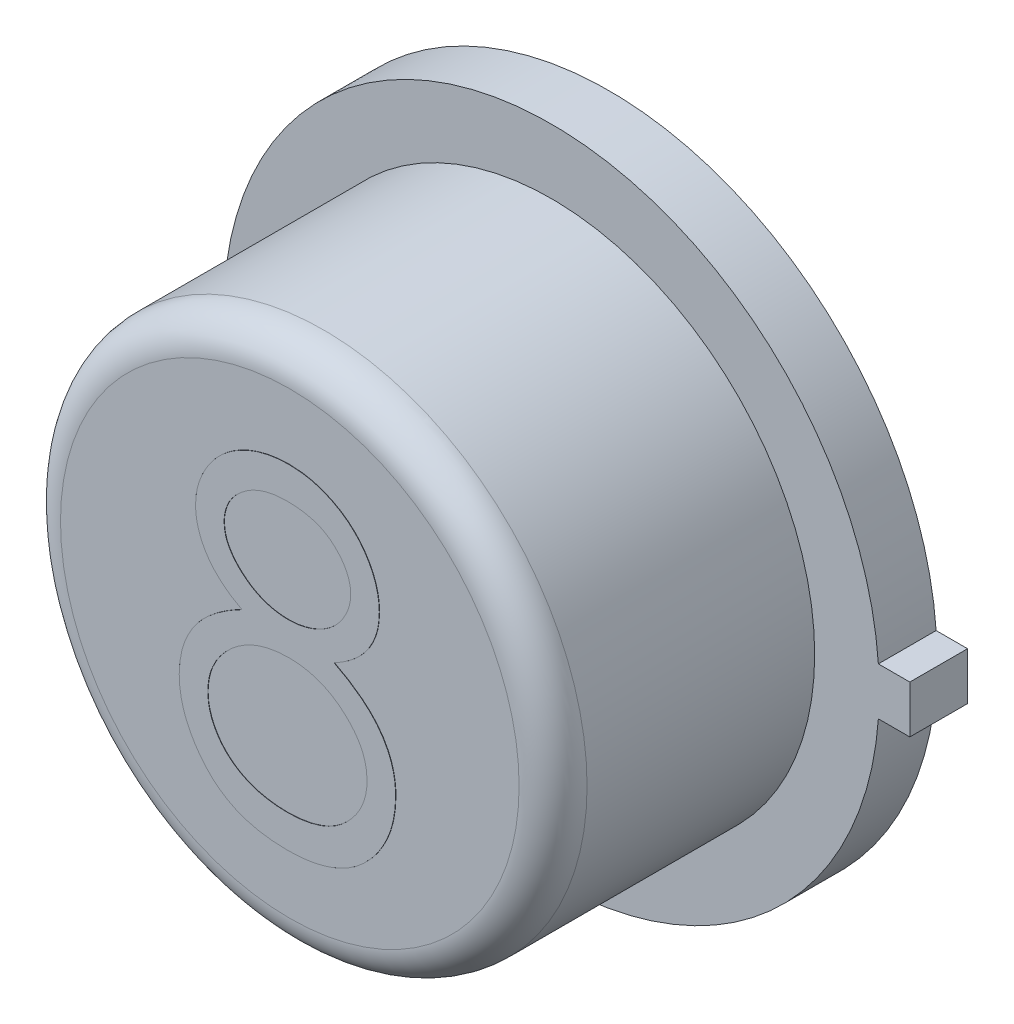
from build123d import *

# Parameters (mm, degrees)
BOSS_EXTRUDE1_DEPTH = 0.4318
SKETCH2_R           = 1.9685
BOSS_EXTRUDE2_DEPTH = 1.9558
SKETCH3_R           = 1.757566481
BOSS_EXTRUDE3_DEPTH = 0.00254
FILLET1_R           = 0.254
BOSS_EXTRUDE6_DEPTH = 0.00254


with BuildPart() as part:
    # Sketch1 → Boss-Extrude1 (new body)
    with BuildSketch(Plane.XY):
        with BuildLine():
            Line((2.6797, 0.1778), (2.4511, 0.1778))
            Line((2.4511, 0.1778), (2.44464279, 0.1778))
            ThreePointArc((2.44464279, 0.1778), (-2.4511, 0), (2.44464279, -0.1778))
            Line((2.44464279, -0.1778), (2.4511, -0.1778))
            Line((2.4511, -0.1778), (2.6797, -0.1778))
            Line((2.6797, -0.1778), (2.6797, 0.1778))
        make_face()
    extrude(amount=BOSS_EXTRUDE1_DEPTH)

    # Sketch2 → Boss-Extrude2 (add)
    with BuildSketch(Plane.XY.offset(0.4318)):
        Circle(SKETCH2_R)
    extrude(amount=BOSS_EXTRUDE2_DEPTH)

    # Sketch3 → Boss-Extrude3 (add)
    with BuildSketch(Plane(origin=(0, 0, 0), x_dir=(-1, 0, 0), z_dir=(0, 0, -1))):
        Circle(SKETCH3_R)
    extrude(amount=BOSS_EXTRUDE3_DEPTH)

    # Fillet1
    fillet1_edges = [part.edges().sort_by_distance(p)[0] for p in [
        (-1.9685, 0, 2.3876),
    ]]
    fillet(fillet1_edges, radius=FILLET1_R)

    # Sketch4 → Boss-Extrude6 (add)
    with BuildSketch(Plane.XY.offset(2.3876)):
        with BuildLine():
            add(Edge.make_bspline(
                [(0.333432242, 0.108432561), (0.352923485, 0.098269416), (0.39093792, 0.078447889), (0.445078842, 0.046531772), (0.494557816, 0.012894259), (0.540747645, -0.020875853), (0.582836817, -0.056071851), (0.620354712, -0.092833695), (0.654228075, -0.130243776), (0.683773798, -0.168935578), (0.709761289, -0.208806309), (0.732221331, -0.249960617), (0.751419106, -0.292308314), (0.766633891, -0.336311657), (0.779167289, -0.381324264), (0.787791227, -0.427927355), (0.792429166, -0.475813844), (0.793306019, -0.508177278), (0.79375, -0.524563983)],
                knots=[0, 0, 0, 0, 6.594e-05, 0.000128605, 0.000188405, 0.000245362, 0.000300208, 0.000352831, 0.000402824, 0.000451482, 0.000498716, 0.000545466, 0.00059201, 0.000638024, 0.000685007, 0.000732067, 0.000780006, 0.000829176, 0.000829176, 0.000829176, 0.000829176], degree=3))
            add(Edge.make_bspline(
                [(0.79375, -0.524563983), (0.793225159, -0.547490476), (0.7921863, -0.592870609), (0.783137561, -0.659849124), (0.769589624, -0.724899283), (0.74980517, -0.788006824), (0.724146595, -0.848823522), (0.692525748, -0.907401438), (0.656731339, -0.964700646), (0.627984726, -0.999956346), (0.613439002, -1.017795654)],
                knots=[0, 0, 0, 0, 6.875e-05, 0.000136081, 0.000202413, 0.000267891, 0.00033416, 0.0004001, 0.000467454, 0.000536443, 0.000536443, 0.000536443, 0.000536443], degree=3))
            add(Edge.make_bspline(
                [(0.613439002, -1.017795654), (0.594500258, -1.038610347), (0.556856801, -1.079982519), (0.49237056, -1.133697267), (0.421598528, -1.178838551), (0.344814555, -1.215626751), (0.262223891, -1.244260166), (0.173844135, -1.264835879), (0.079502988, -1.276621317), (0.01466123, -1.278324924), (-0.018603516, -1.279198899)],
                knots=[0, 0, 0, 0, 8.4349e-05, 0.000167656, 0.000250888, 0.000335588, 0.000422483, 0.000512618, 0.000607343, 0.000707132, 0.000707132, 0.000707132, 0.000707132], degree=3))
            add(Edge.make_bspline(
                [(-0.018603516, -1.279198899), (-0.05058941, -1.278414803), (-0.112830713, -1.27688903), (-0.203425626, -1.26655139), (-0.287873643, -1.248434931), (-0.366665782, -1.223639581), (-0.439327036, -1.191383693), (-0.50565036, -1.151236901), (-0.566592652, -1.104815152), (-0.620304449, -1.050785216), (-0.667989623, -0.992915485), (-0.709877887, -0.933213051), (-0.744694537, -0.871672463), (-0.774172436, -0.809211345), (-0.796738537, -0.74495423), (-0.812367844, -0.679231721), (-0.822293788, -0.612158615), (-0.823614453, -0.566893329), (-0.824278846, -0.544121525)],
                knots=[0, 0, 0, 0, 9.5956e-05, 0.00018672, 0.000273075, 0.000354689, 0.00043412, 0.000510937, 0.000586788, 0.000663356, 0.000738906, 0.000811553, 0.000881843, 0.000950774, 0.001018511, 0.001085731, 0.001153191, 0.001221486, 0.001221486, 0.001221486, 0.001221486], degree=3))
            add(Edge.make_bspline(
                [(-0.824278846, -0.544121525), (-0.823885681, -0.527412504), (-0.823108647, -0.494389579), (-0.817730527, -0.445601625), (-0.809084235, -0.398115327), (-0.79734164, -0.351755285), (-0.781427388, -0.306859012), (-0.762212651, -0.263213779), (-0.739807162, -0.220770312), (-0.713898369, -0.179296502), (-0.683757171, -0.139373476), (-0.649627973, -0.100323701), (-0.610828655, -0.06275311), (-0.567790855, -0.026202674), (-0.52100641, 0.00997598), (-0.469260126, 0.043827645), (-0.413923776, 0.077748867), (-0.374595455, 0.098029174), (-0.354420823, 0.108432561)],
                knots=[0, 0, 0, 0, 5.0123e-05, 9.906e-05, 0.000147059, 0.000194841, 0.000242363, 0.00028978, 0.00033779, 0.00038623, 0.000436316, 0.000487697, 0.000541669, 0.000598168, 0.000657034, 0.000718951, 0.000783578, 0.000851651, 0.000851651, 0.000851651, 0.000851651], degree=3))
            add(Edge.make_bspline(
                [(-0.354420823, 0.108432561), (-0.382037455, 0.123492109), (-0.435510984, 0.152651609), (-0.506315371, 0.206227561), (-0.567132921, 0.264253735), (-0.616291934, 0.327955435), (-0.65498536, 0.395342683), (-0.681531947, 0.465993862), (-0.699490983, 0.538598932), (-0.70127, 0.588201184), (-0.702163462, 0.613112549)],
                knots=[0, 0, 0, 0, 9.4253e-05, 0.000182501, 0.000265487, 0.000345731, 0.000423061, 0.000497652, 0.000571591, 0.00064619, 0.00064619, 0.00064619, 0.00064619], degree=3))
            add(Edge.make_bspline(
                [(-0.702163462, 0.613112549), (-0.701050789, 0.638488209), (-0.698814123, 0.689497712), (-0.680727971, 0.765429735), (-0.651254855, 0.840008148), (-0.611167533, 0.912871481), (-0.561238017, 0.981553681), (-0.50133492, 1.04315386), (-0.432888749, 1.097113994), (-0.356241164, 1.142409569), (-0.273757225, 1.179273808), (-0.186728849, 1.204704485), (-0.09667236, 1.221329771), (-0.035373733, 1.223212085), (-0.004293119, 1.224166485)],
                knots=[0, 0, 0, 0, 7.6061e-05, 0.000152895, 0.000232796, 0.000316055, 0.000401733, 0.000486743, 0.000573013, 0.000662428, 0.000753193, 0.000843293, 0.000933872, 0.001027038, 0.001027038, 0.001027038, 0.001027038], degree=3))
            add(Edge.make_bspline(
                [(-0.004293119, 1.224166485), (0.025985369, 1.223182456), (0.085691099, 1.221242061), (0.173453515, 1.205058488), (0.257426512, 1.178028226), (0.337320511, 1.141358865), (0.411705228, 1.096192036), (0.477429299, 1.041490727), (0.535485931, 0.980162279), (0.583508527, 0.911500906), (0.623080065, 0.838917553), (0.650635142, 0.762974373), (0.668291753, 0.685312246), (0.67051881, 0.632762818), (0.671634615, 0.606434364)],
                knots=[0, 0, 0, 0, 9.0784e-05, 0.000179016, 0.000266663, 0.000354818, 0.000442194, 0.000526906, 0.0006106, 0.000694776, 0.00077758, 0.000857866, 0.000936459, 0.001015374, 0.001015374, 0.001015374, 0.001015374], degree=3))
            add(Edge.make_bspline(
                [(0.671634615, 0.606434364), (0.670658602, 0.580596669), (0.668741767, 0.529852906), (0.652617343, 0.455880041), (0.625462035, 0.38660469), (0.588386542, 0.32124077), (0.540063845, 0.260973716), (0.481138975, 0.205037153), (0.412081719, 0.152971579), (0.36019708, 0.123589428), (0.333432242, 0.108432561)],
                knots=[0, 0, 0, 0, 7.7454e-05, 0.000152115, 0.000225817, 0.000299952, 0.000376684, 0.000456642, 0.000543172, 0.000635369, 0.000635369, 0.000635369, 0.000635369], degree=3))
        make_face()
        with BuildLine():
            add(Edge.make_bspline(
                [(-0.01621845, 0.979935716), (-0.032921766, 0.979492504), (-0.065600756, 0.978625387), (-0.113517405, 0.974095136), (-0.159082533, 0.965282322), (-0.202772212, 0.953553842), (-0.24398744, 0.937709693), (-0.283287967, 0.919071302), (-0.32000493, 0.896411283), (-0.354581567, 0.870992325), (-0.385708433, 0.843034473), (-0.41333403, 0.813905853), (-0.436281193, 0.783034381), (-0.455767376, 0.751187979), (-0.46990623, 0.717421462), (-0.480495516, 0.682770073), (-0.487653819, 0.646795927), (-0.488190206, 0.622210194), (-0.488461538, 0.609773457)],
                knots=[0, 0, 0, 0, 5.0123e-05, 9.8062e-05, 0.000144184, 0.000189201, 0.000233586, 0.00027647, 0.000319502, 0.000362815, 0.000405044, 0.000444868, 0.000483029, 0.000520251, 0.00055658, 0.000592492, 0.000628886, 0.000666142, 0.000666142, 0.000666142, 0.000666142], degree=3))
            add(Edge.make_bspline(
                [(-0.488461538, 0.609773457), (-0.487993883, 0.597336181), (-0.48706973, 0.572758339), (-0.479922491, 0.536464098), (-0.469270238, 0.500798663), (-0.452498985, 0.466610097), (-0.432383301, 0.432712418), (-0.407556065, 0.399952823), (-0.377967994, 0.368217302), (-0.344611825, 0.337775782), (-0.308272904, 0.30926966), (-0.269775546, 0.284522906), (-0.229602912, 0.263816841), (-0.188167754, 0.2465838), (-0.145047775, 0.23318761), (-0.100507192, 0.223683942), (-0.05453852, 0.217777084), (-0.023391374, 0.217071539), (-0.007632212, 0.216714562)],
                knots=[0, 0, 0, 0, 3.7283e-05, 7.3677e-05, 0.000110642, 0.000148624, 0.000187564, 0.000228778, 0.000271648, 0.000317566, 0.00036413, 0.000410045, 0.000454635, 0.000499547, 0.000544508, 0.000589885, 0.000636034, 0.000683297, 0.000683297, 0.000683297, 0.000683297], degree=3))
            add(Edge.make_bspline(
                [(-0.007632212, 0.216714562), (0.012608484, 0.217308424), (0.052889959, 0.218490281), (0.112271076, 0.229478847), (0.170007982, 0.246763945), (0.225483558, 0.270413136), (0.277261856, 0.300095662), (0.323417331, 0.335632769), (0.363556289, 0.376203893), (0.397261597, 0.421177429), (0.42339401, 0.469041635), (0.443737919, 0.517075048), (0.455617781, 0.565790137), (0.45716734, 0.598424804), (0.457932692, 0.614543589)],
                knots=[0, 0, 0, 0, 6.0673e-05, 0.000120746, 0.000180508, 0.000241201, 0.000301256, 0.000359075, 0.000415405, 0.000471979, 0.000527067, 0.000578622, 0.000628142, 0.000676471, 0.000676471, 0.000676471, 0.000676471], degree=3))
            add(Edge.make_bspline(
                [(0.457932692, 0.614543589), (0.457570812, 0.625856592), (0.456852531, 0.648311281), (0.450933386, 0.681470776), (0.441152686, 0.713875904), (0.42791084, 0.745794363), (0.410487033, 0.776778325), (0.389828541, 0.807314855), (0.364733907, 0.836717008), (0.336569548, 0.86566998), (0.304629904, 0.892465181), (0.268976528, 0.916029154), (0.229792209, 0.936040061), (0.187076019, 0.952292946), (0.140985276, 0.964500151), (0.091732267, 0.973641667), (0.038906313, 0.978794087), (0.002555, 0.97954692), (-0.01621845, 0.979935716)],
                knots=[0, 0, 0, 0, 3.3922e-05, 6.733e-05, 0.000100683, 0.000135322, 0.000170765, 0.00020715, 0.00024575, 0.000286564, 0.000328218, 0.000370554, 0.000414501, 0.000459948, 0.000507391, 0.000557352, 0.000610085, 0.000666405, 0.000666405, 0.000666405, 0.000666405], degree=3))
        make_face(mode=Mode.SUBTRACT)
        with BuildLine():
            add(Edge.make_bspline(
                [(-0.002385066, -0.027516207), (-0.023561717, -0.027892881), (-0.065105138, -0.028631823), (-0.125967798, -0.036857001), (-0.184378612, -0.048306999), (-0.24014064, -0.065677087), (-0.293230335, -0.088262556), (-0.343935096, -0.115432306), (-0.391867025, -0.147548866), (-0.436364237, -0.184204206), (-0.476997431, -0.223705371), (-0.512646988, -0.265521573), (-0.542921194, -0.308875654), (-0.567300602, -0.354318224), (-0.587311084, -0.400887045), (-0.600451419, -0.449741855), (-0.608875405, -0.499943445), (-0.610006588, -0.534070226), (-0.610576923, -0.551276724)],
                knots=[0, 0, 0, 0, 6.3488e-05, 0.000124547, 0.000183952, 0.000241889, 0.000299388, 0.000356799, 0.000414217, 0.000472179, 0.000529524, 0.000584006, 0.000636802, 0.000687816, 0.000738489, 0.000788484, 0.000839223, 0.00089082, 0.00089082, 0.00089082, 0.00089082], degree=3))
            add(Edge.make_bspline(
                [(-0.610576923, -0.551276724), (-0.60964942, -0.572660965), (-0.607809276, -0.615086801), (-0.593211099, -0.677790605), (-0.569782636, -0.738492786), (-0.537108338, -0.796698669), (-0.49664915, -0.851093295), (-0.446897035, -0.898506551), (-0.390943894, -0.940635271), (-0.326896532, -0.97470792), (-0.256936451, -1.001918705), (-0.181082257, -1.020666601), (-0.100422571, -1.033077302), (-0.044728813, -1.034327921), (-0.01621845, -1.03496813)],
                knots=[0, 0, 0, 0, 6.4098e-05, 0.000127168, 0.000192101, 0.000258726, 0.000326844, 0.000394649, 0.000464198, 0.000536341, 0.000611548, 0.000688832, 0.000770324, 0.000855795, 0.000855795, 0.000855795, 0.000855795], degree=3))
            add(Edge.make_bspline(
                [(-0.01621845, -1.03496813), (0.006063497, -1.034540316), (0.049475875, -1.033706796), (0.112807565, -1.026349214), (0.172573231, -1.014681344), (0.228656974, -0.997710825), (0.281686622, -0.976993966), (0.330763065, -0.95034296), (0.377148813, -0.920031469), (0.418558154, -0.884069045), (0.456272533, -0.845642817), (0.489156434, -0.804964234), (0.517702554, -0.763138848), (0.540107365, -0.719221465), (0.558018619, -0.674054654), (0.570893395, -0.627221922), (0.578837391, -0.578579629), (0.579640822, -0.54558294), (0.580048077, -0.528857102)],
                knots=[0, 0, 0, 0, 6.6824e-05, 0.000130195, 0.000191003, 0.000249257, 0.000305771, 0.000361469, 0.000416506, 0.00047166, 0.000525632, 0.000577856, 0.000628394, 0.00067725, 0.000725438, 0.000773927, 0.000822706, 0.00087285, 0.00087285, 0.00087285, 0.00087285], degree=3))
            add(Edge.make_bspline(
                [(0.580048077, -0.528857102), (0.579431776, -0.512611983), (0.578216539, -0.480579446), (0.57050354, -0.433113291), (0.556953631, -0.387255305), (0.538361242, -0.342453783), (0.513609194, -0.29961649), (0.48445938, -0.257627452), (0.449288918, -0.217652085), (0.409547491, -0.179379889), (0.366236662, -0.143990611), (0.320198837, -0.112684359), (0.27178839, -0.08631908), (0.221107763, -0.064876608), (0.168269488, -0.048012275), (0.11331243, -0.036231214), (0.056172244, -0.028815592), (0.017354555, -0.027954229), (-0.002385066, -0.027516207)],
                knots=[0, 0, 0, 0, 4.8739e-05, 9.6106e-05, 0.000143807, 0.000191912, 0.000241257, 0.000291942, 0.000345028, 0.000400691, 0.000457311, 0.000512614, 0.000567473, 0.000622404, 0.000677467, 0.000733605, 0.000790819, 0.000850016, 0.000850016, 0.000850016, 0.000850016], degree=3))
        make_face(mode=Mode.SUBTRACT)
    extrude(amount=BOSS_EXTRUDE6_DEPTH)


solid = part.part
